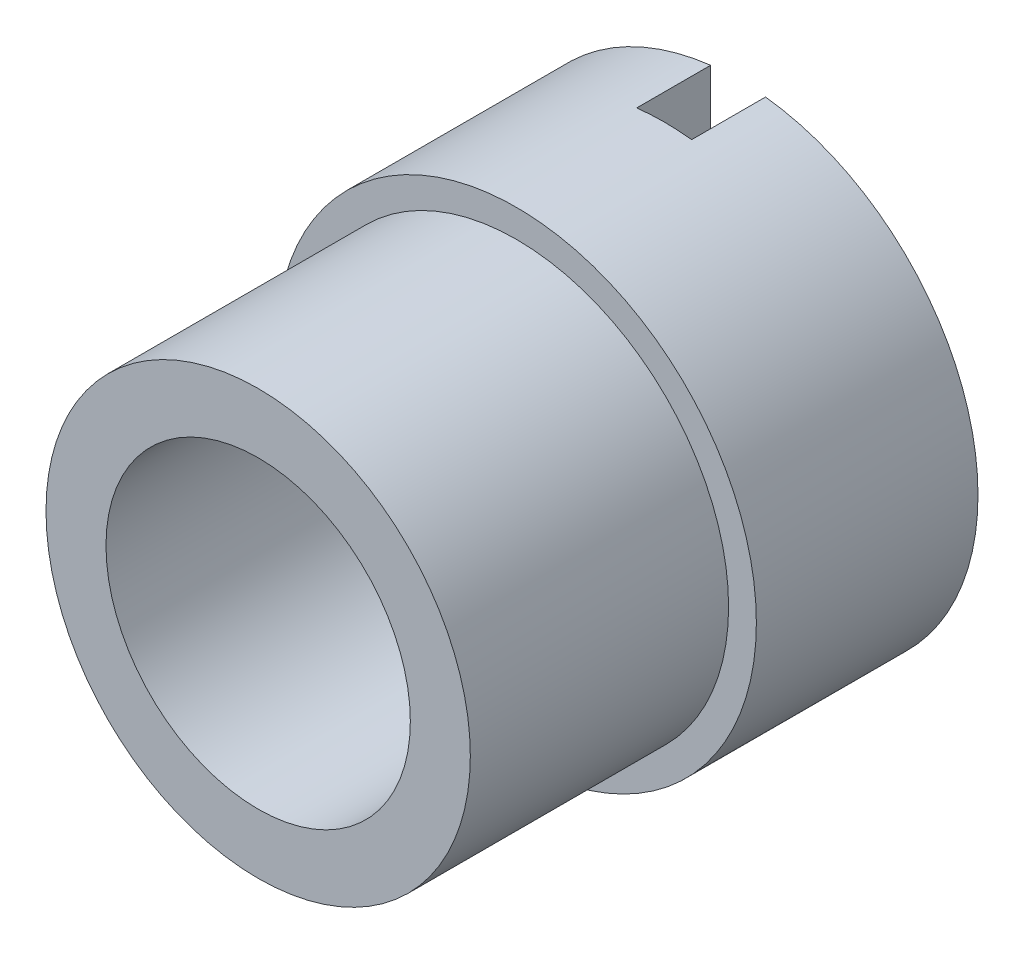
from build123d import *

# Parameters (mm, degrees)
SKETCH1_R               = 10.3124
SKETCH1_R_2             = 6.5405
BOSS_EXTRUDE1_DEPTH     = 4.7625
SKETCH2_R               = 9.1186
SKETCH2_R_2             = 6.5405
BOSS_EXTRUDE2_DEPTH     = 11.0998
SKETCH3_W               = 2.3622
SKETCH3_H               = 3.175
CUT_EXTRUDE1_DEPTH      = 11.3124
CUT_EXTRUDE1_DEPTH_BACK = 11.3124


with BuildPart() as part:
    # Sketch1 → Boss-Extrude1 (new body, symmetric)
    with BuildSketch(Plane.XY):
        Circle(SKETCH1_R)
        Circle(SKETCH1_R_2, mode=Mode.SUBTRACT)
    extrude(amount=BOSS_EXTRUDE1_DEPTH, both=True)

    # Sketch2 → Boss-Extrude2 (add)
    with BuildSketch(Plane.XY.offset(4.7625)):
        Circle(SKETCH2_R)
        Circle(SKETCH2_R_2, mode=Mode.SUBTRACT)
    extrude(amount=BOSS_EXTRUDE2_DEPTH)

    # Sketch3 → Cut-Extrude1 (cut, two sides)
    with BuildSketch(Plane(origin=(0, 0, 0), x_dir=(1, 0, 0), z_dir=(0, 1, 0))) as cut_extrude1_sk:
        with Locations((0, 3.175)):
            Rectangle(SKETCH3_W, SKETCH3_H)
    extrude(amount=CUT_EXTRUDE1_DEPTH, mode=Mode.SUBTRACT)
    extrude(cut_extrude1_sk.sketch, amount=-CUT_EXTRUDE1_DEPTH_BACK, mode=Mode.SUBTRACT)


solid = part.part
